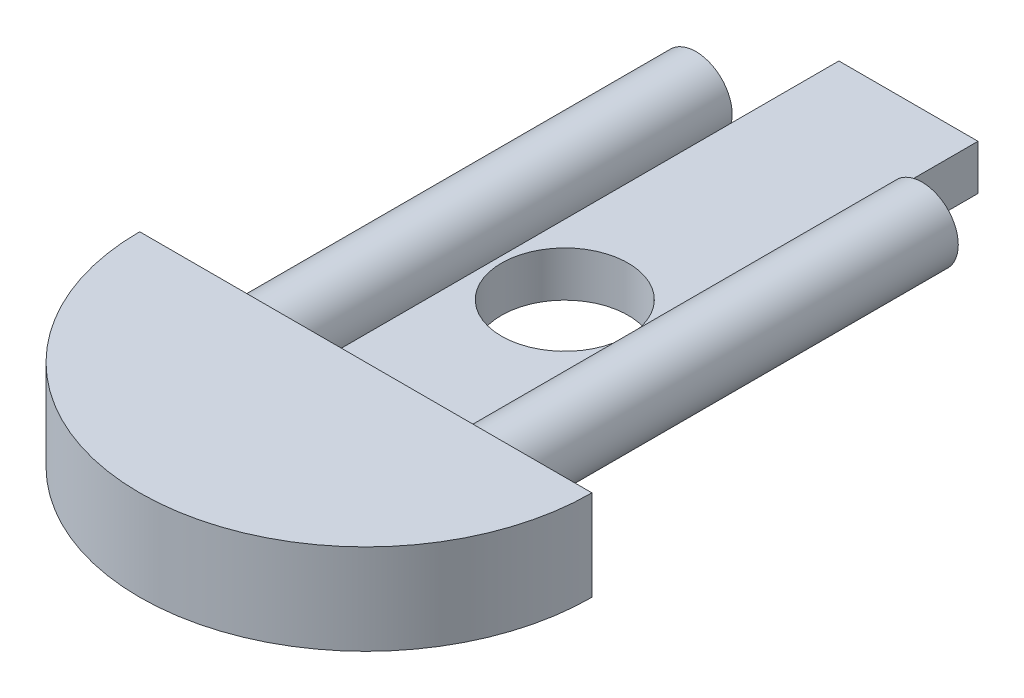
from build123d import *

# Parameters (mm, degrees)
SKETCH2_W           = 31.75
SKETCH2_H           = 12.7
REVOLVE1_ANGLE      = 180
SKETCH3_R           = 5.08
BOSS_EXTRUDE1_DEPTH = 62.23
SKETCH4_W           = 19.5326
SKETCH4_H           = 6.35
BOSS_EXTRUDE2_DEPTH = 76.2
SKETCH5_R           = 8.89
CUT_EXTRUDE1_DEPTH  = 76.2


with BuildPart() as part:
    # Sketch2 → Revolve1 (revolve)
    with BuildSketch(Plane.XY):
        with Locations((15.875, 6.35)):
            Rectangle(SKETCH2_W, SKETCH2_H)
    revolve(axis=Axis((31.75, 0, 0), (0, 1, 0)), revolution_arc=REVOLVE1_ANGLE)

    # Sketch3 → Boss-Extrude1 (add)
    with BuildSketch(Plane(origin=(0, 0, 0), x_dir=(-1, 0, 0), z_dir=(0, 0, -1))):
        with Locations((-47.625, 6.35)):
            Circle(SKETCH3_R)
        with Locations((-15.875, 6.35)):
            Circle(SKETCH3_R)
    extrude(amount=BOSS_EXTRUDE1_DEPTH)

    # Sketch4 → Boss-Extrude2 (add)
    with BuildSketch(Plane(origin=(0, 0, 0), x_dir=(-1, 0, 0), z_dir=(0, 0, -1))):
        with Locations((-31.7373, 3.175)):
            Rectangle(SKETCH4_W, SKETCH4_H)
    extrude(amount=BOSS_EXTRUDE2_DEPTH)

    # Sketch5 → Cut-Extrude1 (cut)
    with BuildSketch(Plane(origin=(0, 6.35, 0), x_dir=(1, 0, 0), z_dir=(0, 1, 0))):
        with Locations((31.75, 27.94)):
            Circle(SKETCH5_R)
    extrude(amount=-CUT_EXTRUDE1_DEPTH, mode=Mode.SUBTRACT)


solid = part.part
